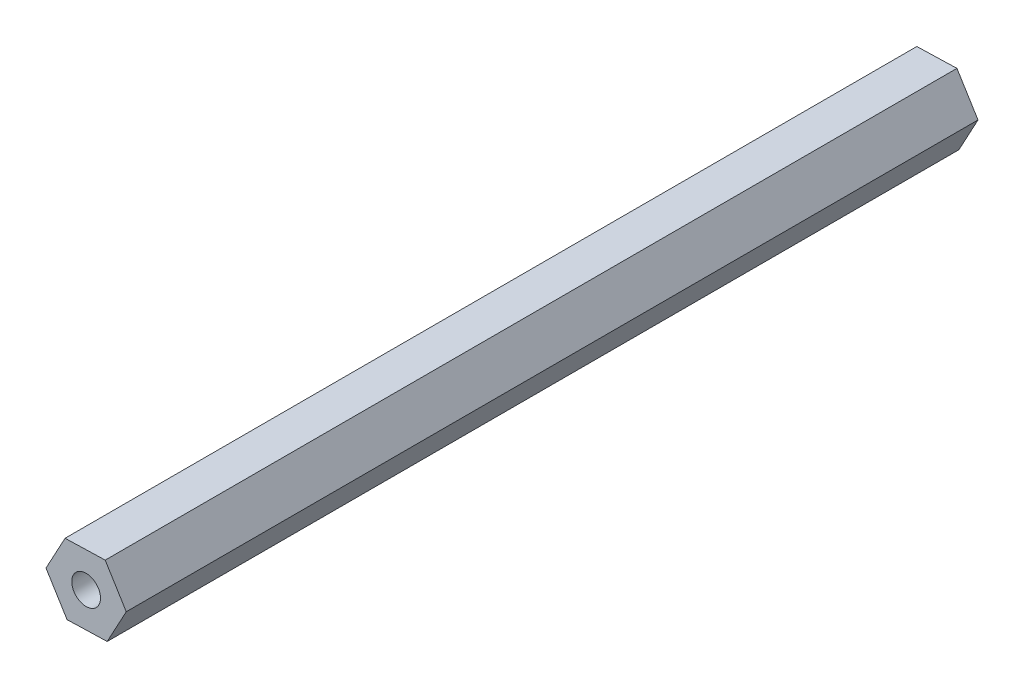
from build123d import *

# Parameters (mm, degrees)
BOSS_EXTRUDE1_DEPTH = 155.575
SKETCH3_R           = 2.6289
CUT_EXTRUDE2_DEPTH  = 25.4
SKETCH4_R           = 2.6289
CUT_EXTRUDE3_DEPTH  = 25.4


with BuildPart() as part:
    # Sketch1 → Boss-Extrude1 (new body)
    with BuildSketch(Plane.XY):
        Polygon((3.484491601, 6.45148445), (-3.844903625, 6.243400471), (-7.329395227, -0.208083979), (-3.484491601, -6.45148445), (3.844903625, -6.243400471), (7.329395227, 0.208083979), align=None)
    extrude(amount=BOSS_EXTRUDE1_DEPTH)

    # Sketch3 → Cut-Extrude2 (cut)
    with BuildSketch(Plane.XY.offset(155.575)):
        Circle(SKETCH3_R)
    extrude(amount=-CUT_EXTRUDE2_DEPTH, mode=Mode.SUBTRACT)

    # Sketch4 → Cut-Extrude3 (cut)
    with BuildSketch(Plane(origin=(0, 0, 0), x_dir=(-1, 0, 0), z_dir=(0, 0, -1))):
        Circle(SKETCH4_R)
    extrude(amount=-CUT_EXTRUDE3_DEPTH, mode=Mode.SUBTRACT)


solid = part.part
